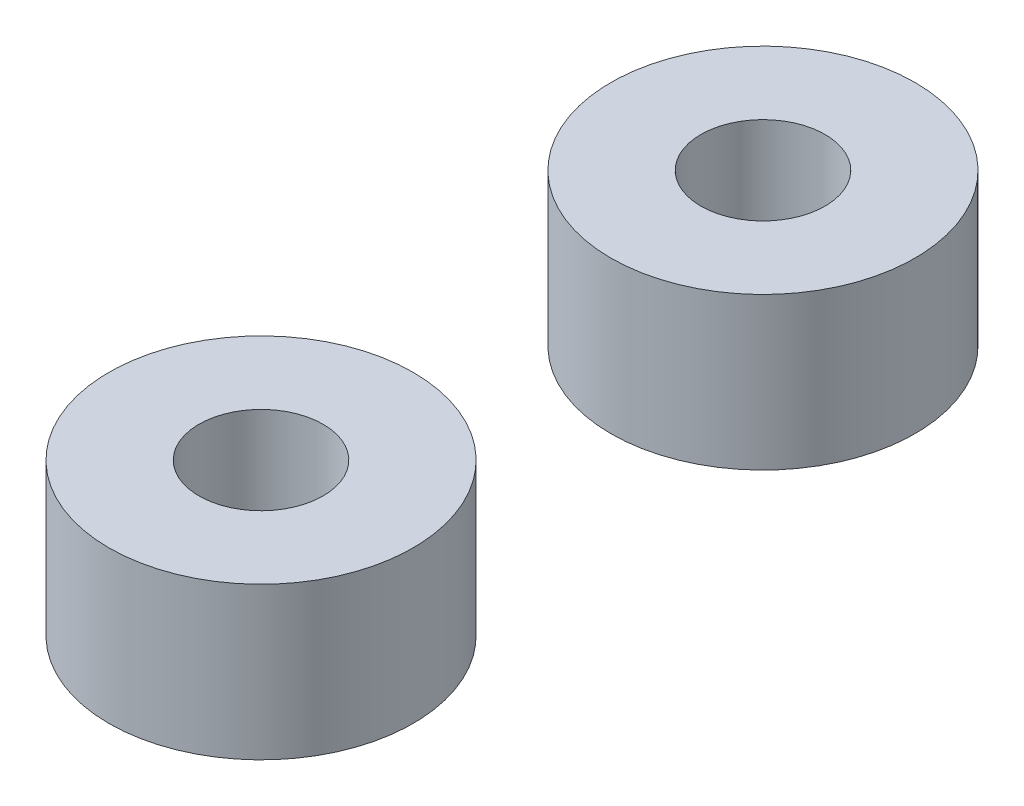
from build123d import *

# Parameters (mm, degrees)
SKETCH_1_R          = 3
SKETCH_1_R_2        = 1.05
EXTRUDE_1_DEPTH     = 3
EXTRUDE_1_2_DEPTH   = 3
SKETCH_1_R_3        = 1.075
EXTRUDE_1_3_DEPTH   = 3
EXTRUDE_1_4_DEPTH   = 3
SKETCH_1_R_4        = 1.225
EXTRUDE_1_5_DEPTH   = 3
EXTRUDE_1_6_DEPTH   = 3
SKETCH_1_R_5        = 1.125
EXTRUDE_1_7_DEPTH   = 3
EXTRUDE_1_8_DEPTH   = 3
SKETCH_2_W          = 22.049293563
SKETCH_2_H          = 26.57793635
SKETCH_2_W_2        = 15.516169545
SKETCH_2_H_2        = 27.468816898
CUT_EXTRUDE_3_DEPTH = 4


with BuildPart() as part:
    # 草图1 → 凸台-拉伸1 (new body)
    with BuildSketch(Plane(origin=(0, 0, 0), x_dir=(1, 0, 0), z_dir=(0, 1, 0))):
        with Locations((0, 4.950130432)):
            Circle(SKETCH_1_R)
        with Locations((0, 4.950130432)):
            Circle(SKETCH_1_R_2, mode=Mode.SUBTRACT)
    extrude(amount=EXTRUDE_1_DEPTH)


with BuildPart() as body_2:
    # 草图1 → Extrude 1 2 (new body)
    with BuildSketch(Plane(origin=(0, 0, 0), x_dir=(1, 0, 0), z_dir=(0, 1, 0))):
        with Locations((0, -4.950130432)):
            Circle(SKETCH_1_R)
        with Locations((0, -4.950130432)):
            Circle(SKETCH_1_R_2, mode=Mode.SUBTRACT)
    extrude(amount=EXTRUDE_1_2_DEPTH)


with BuildPart() as body_3:
    # 草图1 → Extrude 1 3 (new body)
    with BuildSketch(Plane(origin=(0, 0, 0), x_dir=(1, 0, 0), z_dir=(0, 1, 0))):
        with Locations((10, -4.950130432)):
            Circle(SKETCH_1_R)
        with Locations((10, -4.950130432)):
            Circle(SKETCH_1_R_3, mode=Mode.SUBTRACT)
    extrude(amount=EXTRUDE_1_3_DEPTH)


with BuildPart() as body_4:
    # 草图1 → Extrude 1 4 (new body)
    with BuildSketch(Plane(origin=(0, 0, 0), x_dir=(1, 0, 0), z_dir=(0, 1, 0))):
        with Locations((10, 4.950130432)):
            Circle(SKETCH_1_R)
        with Locations((10, 4.950130432)):
            Circle(SKETCH_1_R_3, mode=Mode.SUBTRACT)
    extrude(amount=EXTRUDE_1_4_DEPTH)


with BuildPart() as body_5:
    # 草图1 → Extrude 1 5 (new body)
    with BuildSketch(Plane(origin=(0, 0, 0), x_dir=(1, 0, 0), z_dir=(0, 1, 0))):
        with Locations((20, -4.950130432)):
            Circle(SKETCH_1_R)
        with Locations((20, -4.950130432)):
            Circle(SKETCH_1_R_4, mode=Mode.SUBTRACT)
    extrude(amount=EXTRUDE_1_5_DEPTH)


with BuildPart() as body_6:
    # 草图1 → Extrude 1 6 (new body)
    with BuildSketch(Plane(origin=(0, 0, 0), x_dir=(1, 0, 0), z_dir=(0, 1, 0))):
        with Locations((20, 4.950130432)):
            Circle(SKETCH_1_R)
        with Locations((20, 4.950130432)):
            Circle(SKETCH_1_R_4, mode=Mode.SUBTRACT)
    extrude(amount=EXTRUDE_1_6_DEPTH)


with BuildPart() as body_7:
    # 草图1 → Extrude 1 7 (new body)
    with BuildSketch(Plane(origin=(0, 0, 0), x_dir=(1, 0, 0), z_dir=(0, 1, 0))):
        with Locations((30, -4.950130432)):
            Circle(SKETCH_1_R)
        with Locations((30, -4.950130432)):
            Circle(SKETCH_1_R_5, mode=Mode.SUBTRACT)
    extrude(amount=EXTRUDE_1_7_DEPTH)


with BuildPart() as body_8:
    # 草图1 → Extrude 1 8 (new body)
    with BuildSketch(Plane(origin=(0, 0, 0), x_dir=(1, 0, 0), z_dir=(0, 1, 0))):
        with Locations((30, 4.950130432)):
            Circle(SKETCH_1_R)
        with Locations((30, 4.950130432)):
            Circle(SKETCH_1_R_5, mode=Mode.SUBTRACT)
    extrude(amount=EXTRUDE_1_8_DEPTH)


with BuildPart() as cut_extrude_3_tool:
    # 草图2 → 切除-拉伸3 (new body, through all)
    with BuildSketch(Plane(origin=(0, 0, 0), x_dir=(1, 0, 0), z_dir=(0, 1, 0))):
        with Locations((4.346553446, -2.004481233)):
            Rectangle(SKETCH_2_W, SKETCH_2_H)
        with Locations((33.003211075, -0.668160411)):
            Rectangle(SKETCH_2_W_2, SKETCH_2_H_2)
    extrude(amount=CUT_EXTRUDE_3_DEPTH)


with BuildPart() as part_1:
    add(part.part)

    # 切除-拉伸3: cut by cut_extrude_3_tool
    add(cut_extrude_3_tool.part, mode=Mode.SUBTRACT)


with BuildPart() as body_2_1:
    add(body_2.part)

    # 切除-拉伸3: cut by cut_extrude_3_tool
    add(cut_extrude_3_tool.part, mode=Mode.SUBTRACT)


with BuildPart() as body_3_1:
    add(body_3.part)

    # 切除-拉伸3: cut by cut_extrude_3_tool
    add(cut_extrude_3_tool.part, mode=Mode.SUBTRACT)


with BuildPart() as body_4_1:
    add(body_4.part)

    # 切除-拉伸3: cut by cut_extrude_3_tool
    add(cut_extrude_3_tool.part, mode=Mode.SUBTRACT)


with BuildPart() as body_7_1:
    add(body_7.part)

    # 切除-拉伸3: cut by cut_extrude_3_tool
    add(cut_extrude_3_tool.part, mode=Mode.SUBTRACT)


with BuildPart() as body_8_1:
    add(body_8.part)

    # 切除-拉伸3: cut by cut_extrude_3_tool
    add(cut_extrude_3_tool.part, mode=Mode.SUBTRACT)


solid = Compound([body_5.part, body_6.part])
